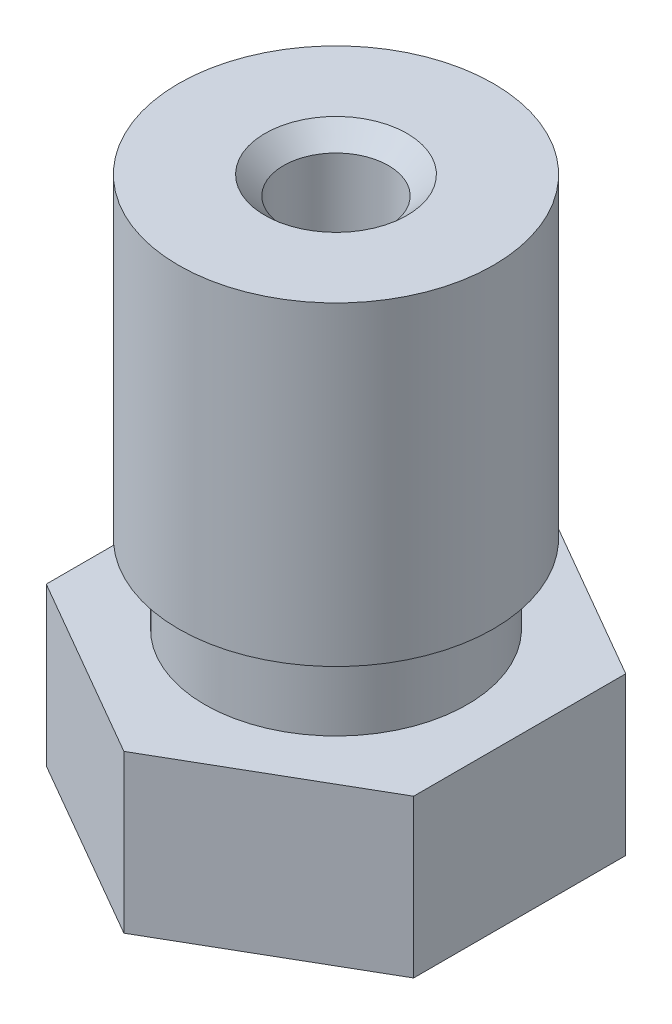
from build123d import *

# Parameters (mm, degrees)
BOSS_EXTRUDE1_DEPTH = 12.5


with BuildPart() as part:
    # Sketch1 → Boss-Extrude1 (new body)
    with BuildSketch(Plane(origin=(0, 0, 0), x_dir=(1, 0, 0), z_dir=(0, 1, 0))):
        Polygon((0, 4.041451884), (-3.5, 2.020725942), (-3.5, -2.020725942), (0, -4.041451884), (3.5, -2.020725942), (3.5, 2.020725942), align=None)
    extrude(amount=BOSS_EXTRUDE1_DEPTH)

    # Sketch2 → Cut-Revolve1 (revolve, cut)
    with BuildSketch(Plane.XY):
        Polygon((-1.353553391, 12.5), (-1, 12.146446609), (-1, 2), (-0.75, 1.75), (-0.75, 1.05), (-0.2, 0.5), (-0.2, 0), (0, 0), (0, 12.5), align=None)
        Polygon((-0.5, 0), (-1.900415076, 2), (-4.539283424, 2), (-4.539283424, 5), (-2.5, 5), (-2.5, 6.211324865), (-3, 6.5), (-3, 12.5), (-7.52819812, 12.5), (-7.52819812, 0), align=None)
    revolve(axis=Axis((0, 0, 0), (0, 1, 0)), mode=Mode.SUBTRACT)


solid = part.part
